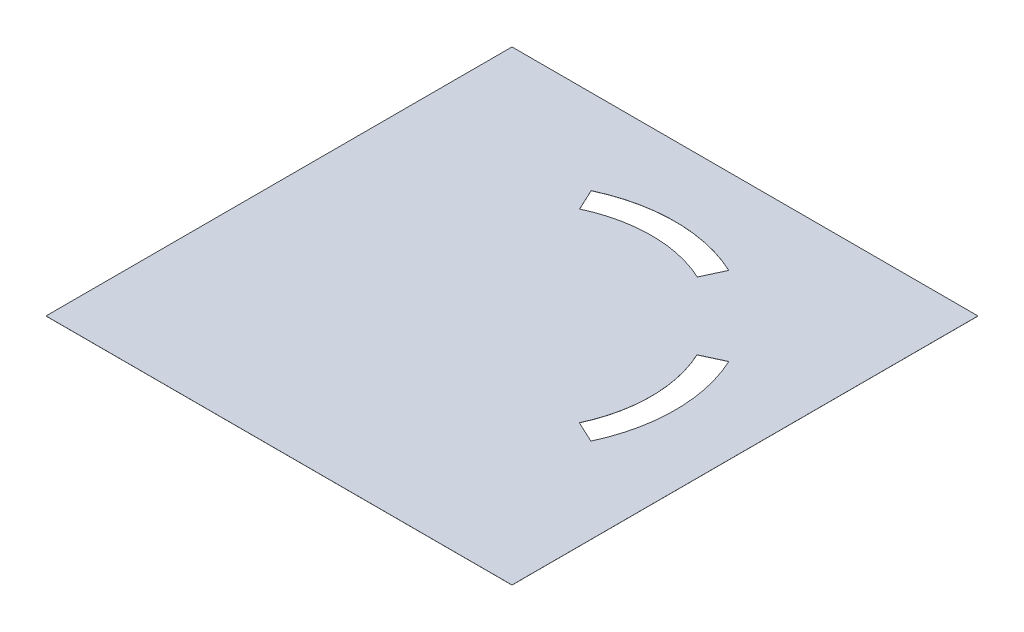
from build123d import *

# Parameters (mm, degrees)
SKETCH1_W           = 107.07
SKETCH1_H           = 107.07
BOSS_EXTRUDE1_DEPTH = 0.02
SCALE1_SCALE        = 0.5


with BuildPart() as part:
    # Sketch1 → Boss-Extrude1 (new body)
    with BuildSketch(Plane(origin=(0, 0, 0), x_dir=(1, 0, 0), z_dir=(0, 1, 0))):
        with Locations((53.535, 53.535)):
            Rectangle(SKETCH1_W, SKETCH1_H)
        with BuildLine():
            Line((40.02098899, 82.576362505), (37.69526755, 87.563888229))
            ThreePointArc((37.69526755, 87.563888229), (53.541760789, 91.075404612), (69.37473245, 87.503415858))
            Line((69.37473245, 87.503415858), (67.077209739, 82.576362505))
            ThreePointArc((67.077209739, 82.576362505), (53.549099365, 85.57547237), (40.02098899, 82.576362505))
        make_face(mode=Mode.SUBTRACT)
        with BuildLine():
            Line((82.518723029, 67.05033201), (87.503415858, 69.37473245))
            ThreePointArc((87.503415858, 69.37473245), (91.015, 53.535), (87.503415858, 37.69526755))
            Line((87.503415858, 37.69526755), (82.518723029, 40.01966799))
            ThreePointArc((82.518723029, 40.01966799), (85.515, 53.535), (82.518723029, 67.05033201))
        make_face(mode=Mode.SUBTRACT)
    extrude(amount=BOSS_EXTRUDE1_DEPTH)


with BuildPart() as part_1:
    # Scale1: scaled about (53.030506877, 0.01, -53.029916686)
    add(part.part.scale(SCALE1_SCALE).moved(Location((26.515253439, 0.005, -26.514958343))))


solid = part_1.part
